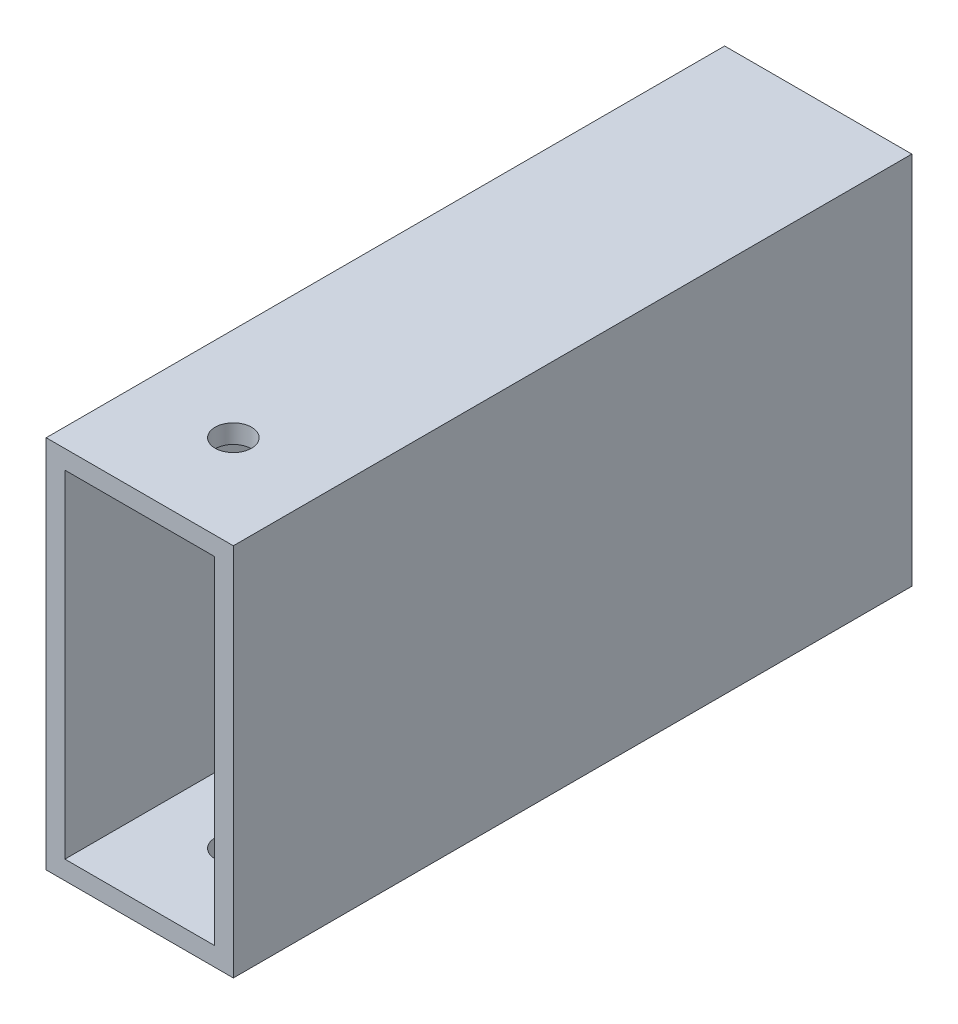
from build123d import *

# Parameters (mm, degrees)
SKETCH1_W           = 25.4
SKETCH1_H           = 50.8
SKETCH1_W_2         = 20.32
SKETCH1_H_2         = 45.72
EXTRUDE_THIN1_DEPTH = 46.0375
SKETCH2_R           = 2.4765
CUT_EXTRUDE1_DEPTH  = 51.8


with BuildPart() as part:
    # Sketch1 → Extrude-Thin1 (new body, symmetric)
    with BuildSketch(Plane.XY):
        Rectangle(SKETCH1_W, SKETCH1_H)
        Rectangle(SKETCH1_W_2, SKETCH1_H_2, mode=Mode.SUBTRACT)
    extrude(amount=EXTRUDE_THIN1_DEPTH, both=True)

    # Sketch2 → Cut-Extrude1 (cut, through all)
    with BuildSketch(Plane.XZ.offset(25.4)):
        with Locations((-5.11e-06, 33.3375)):
            Circle(SKETCH2_R)
    extrude(amount=-CUT_EXTRUDE1_DEPTH, mode=Mode.SUBTRACT)


solid = part.part
